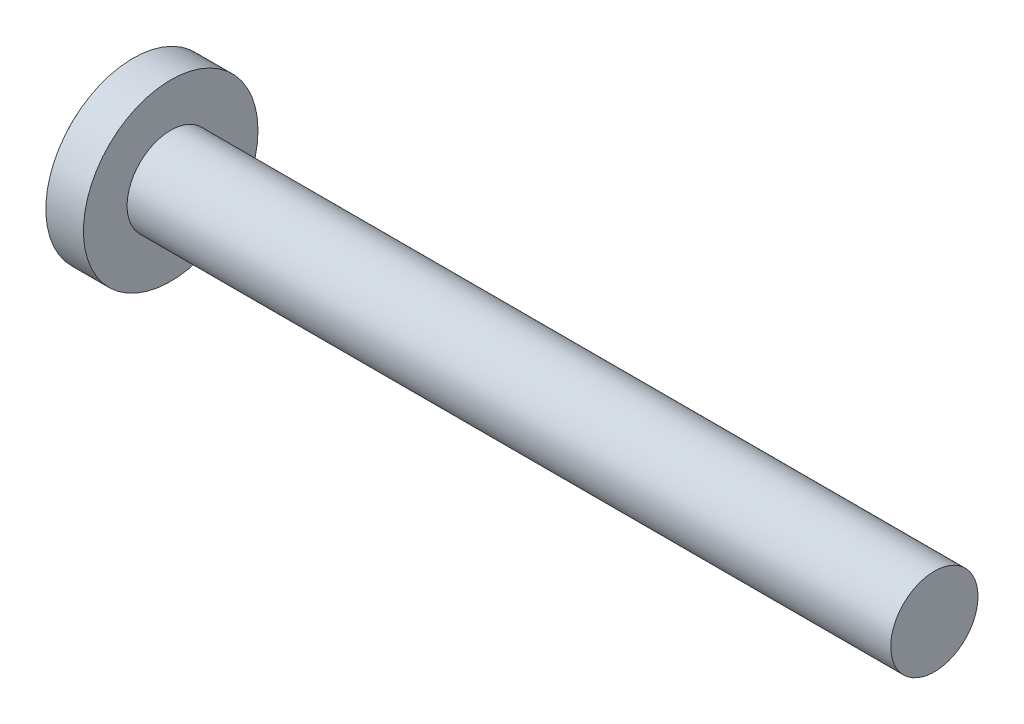
from build123d import *

# Parameters (mm, degrees)
CROSSRECESS_DEPTH = 2.17
FILLET5_R         = 0.3
DRAFT1_ANGLE      = -30


with BuildPart() as part:
    # Sketch1 → Base (revolve)
    with BuildSketch(Plane.XY):
        with BuildLine():
            Line((38.1, 2), (4.5, 2))
            Line((4.5, 2), (3.1, 2))
            Line((3.1, 2), (3.1, 2.35))
            Line((3.1, 2.35), (3.1, 4))
            Line((3.1, 4), (1.376524617, 4))
            ThreePointArc((1.376524617, 4), (0.353757652, 2.115113473), (0, 0))
            Line((0, 0), (38.1, 0))
            Line((38.1, 0), (38.1, 2))
        make_face()
    revolve(axis=Axis((4.515812911, 0, 0), (-1, 0, 0)))

    # Sketch6 → CrossRecess (cut)
    with BuildSketch(Plane(origin=(0, 0, 0), x_dir=(0, 0, -1), z_dir=(1, 0, 0))):
        Polygon((0.44, 0.44), (0.44, 2.2), (-0.44, 2.2), (-0.44, 0.44), (-2.2, 0.44), (-2.2, -0.44), (-0.44, -0.44), (-0.44, -2.2), (0.44, -2.2), (0.44, -0.44), (2.2, -0.44), (2.2, 0.44), align=None)
    extrude(amount=CROSSRECESS_DEPTH, mode=Mode.SUBTRACT)

    # Fillet5
    fillet5_edges = [part.edges().sort_by_distance(p)[0] for p in [
        (1.099926585, 0.44, 0.44),
        (1.099926585, -0.44, 0.44),
        (1.099926585, -0.44, -0.44),
        (1.099926585, 0.44, -0.44),
    ]]
    fillet(fillet5_edges, radius=FILLET5_R)

    # Draft1
    draft1_faces = [part.faces().sort_by_distance(p)[0] for p in [
        (1.27944778, -2.2, 0),
        (1.27944778, 0, -2.2),
        (1.27944778, 0, 2.2),
        (1.27944778, 2.2, 0),
    ]]
    draft(draft1_faces, Plane(origin=(0, 0, 0), x_dir=(0, 0, 1), z_dir=(1, 0, 0)), DRAFT1_ANGLE)


solid = part.part
